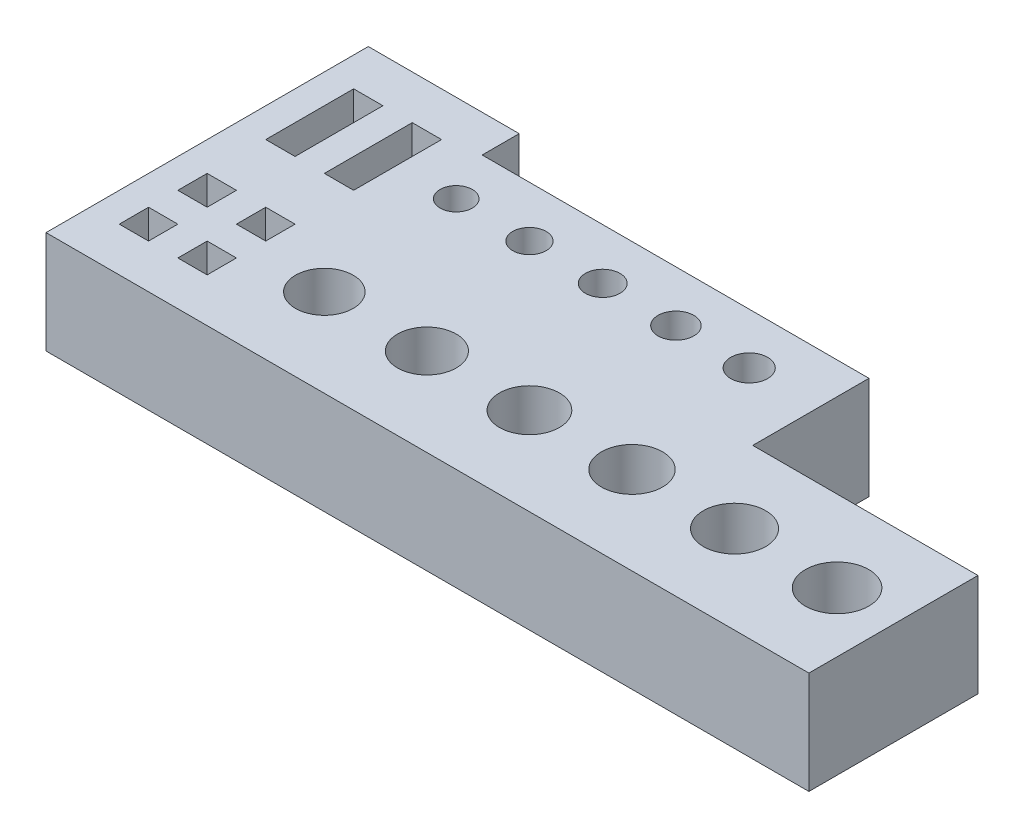
from build123d import *

# Parameters (mm, degrees)
SKETCH1_W           = 66.137036943
SKETCH1_H           = 27.94
SKETCH1_R           = 1.4
SKETCH1_R_2         = 1.45
SKETCH1_R_3         = 1.5
SKETCH1_R_4         = 1.55
SKETCH1_R_5         = 1.6
SKETCH1_R_6         = 2.5
SKETCH1_R_7         = 2.55
SKETCH1_R_8         = 2.6
SKETCH1_R_9         = 2.65
SKETCH1_R_10        = 2.7
SKETCH1_R_11        = 2.75
SKETCH1_W_2         = 2.54
SKETCH1_H_2         = 7.62
SKETCH1_H_3         = 2.54
BOSS_EXTRUDE1_DEPTH = 8.89
SKETCH2_W           = 33.530167106
SKETCH2_H           = 3.206730365
CUT_EXTRUDE1_DEPTH  = 9.89


with BuildPart() as part:
    # Sketch1 → Boss-Extrude1 (new body)
    with BuildSketch(Plane(origin=(0, 0, 0), x_dir=(1, 0, 0), z_dir=(0, 1, 0))):
        with Locations((33.068518471, 13.97)):
            Rectangle(SKETCH1_W, SKETCH1_H)
        with Locations((15.24, 20.32)):
            Circle(SKETCH1_R, mode=Mode.SUBTRACT)
        with Locations((21.59, 20.32)):
            Circle(SKETCH1_R_2, mode=Mode.SUBTRACT)
        with Locations((27.94, 20.32)):
            Circle(SKETCH1_R_3, mode=Mode.SUBTRACT)
        with Locations((34.29, 20.32)):
            Circle(SKETCH1_R_4, mode=Mode.SUBTRACT)
        with Locations((40.64, 20.32)):
            Circle(SKETCH1_R_5, mode=Mode.SUBTRACT)
        with Locations((16.51, 7.62)):
            Circle(SKETCH1_R_6, mode=Mode.SUBTRACT)
        with Locations((25.4, 7.62)):
            Circle(SKETCH1_R_7, mode=Mode.SUBTRACT)
        with Locations((34.29, 7.62)):
            Circle(SKETCH1_R_8, mode=Mode.SUBTRACT)
        with Locations((43.18, 7.62)):
            Circle(SKETCH1_R_9, mode=Mode.SUBTRACT)
        with Locations((52.07, 7.62)):
            Circle(SKETCH1_R_10, mode=Mode.SUBTRACT)
        with Locations((60.96, 7.62)):
            Circle(SKETCH1_R_11, mode=Mode.SUBTRACT)
        with Locations((3.81, 20.32)):
            Rectangle(SKETCH1_W_2, SKETCH1_H_2, mode=Mode.SUBTRACT)
        with Locations((8.89, 20.32)):
            Rectangle(SKETCH1_W_2, SKETCH1_H_2, mode=Mode.SUBTRACT)
        with Locations((3.81, 10.16)):
            Rectangle(SKETCH1_W_2, SKETCH1_H_3, mode=Mode.SUBTRACT)
        with Locations((8.89, 10.16)):
            Rectangle(SKETCH1_W_2, SKETCH1_H_3, mode=Mode.SUBTRACT)
        with Locations((3.81, 5.08)):
            Rectangle(SKETCH1_W_2, SKETCH1_H_3, mode=Mode.SUBTRACT)
        with Locations((8.89, 5.08)):
            Rectangle(SKETCH1_W_2, SKETCH1_H_3, mode=Mode.SUBTRACT)
    extrude(amount=BOSS_EXTRUDE1_DEPTH)

    # Sketch2 → Cut-Extrude1 (cut, through all)
    with BuildSketch(Plane(origin=(0, 8.89, 0), x_dir=(1, 0, 0), z_dir=(0, 1, 0))):
        with Locations((29.845478727, 26.336634818)):
            Rectangle(SKETCH2_W, SKETCH2_H)
        Polygon((66.137036943, 27.94), (46.61056228, 27.94), (46.61056228, 24.733269635), (46.61056228, 14.65880598), (66.137036943, 14.65880598), align=None)
    extrude(amount=-CUT_EXTRUDE1_DEPTH, mode=Mode.SUBTRACT)


solid = part.part
